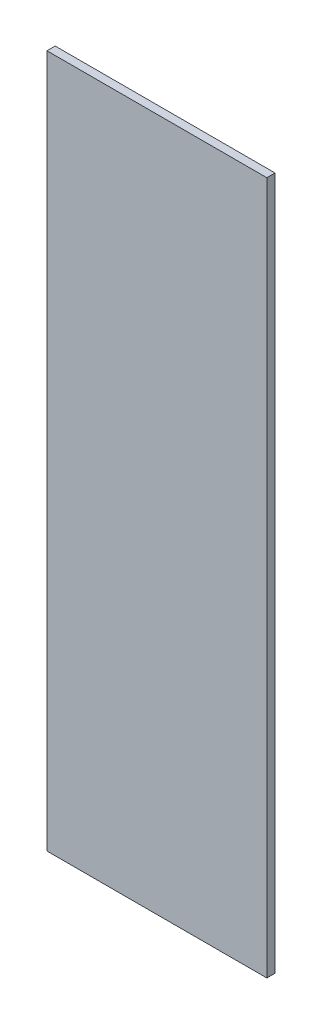
from build123d import *

# Parameters (mm, degrees)
SKETCH3_W           = 85
SKETCH3_H           = 267.9
BOSS_EXTRUDE1_DEPTH = 3.175


with BuildPart() as part:
    # Sketch3 → Boss-Extrude1 (new body)
    with BuildSketch(Plane.XY):
        with Locations((-42.5, 133.95)):
            Rectangle(SKETCH3_W, SKETCH3_H)
    extrude(amount=BOSS_EXTRUDE1_DEPTH)


solid = part.part
